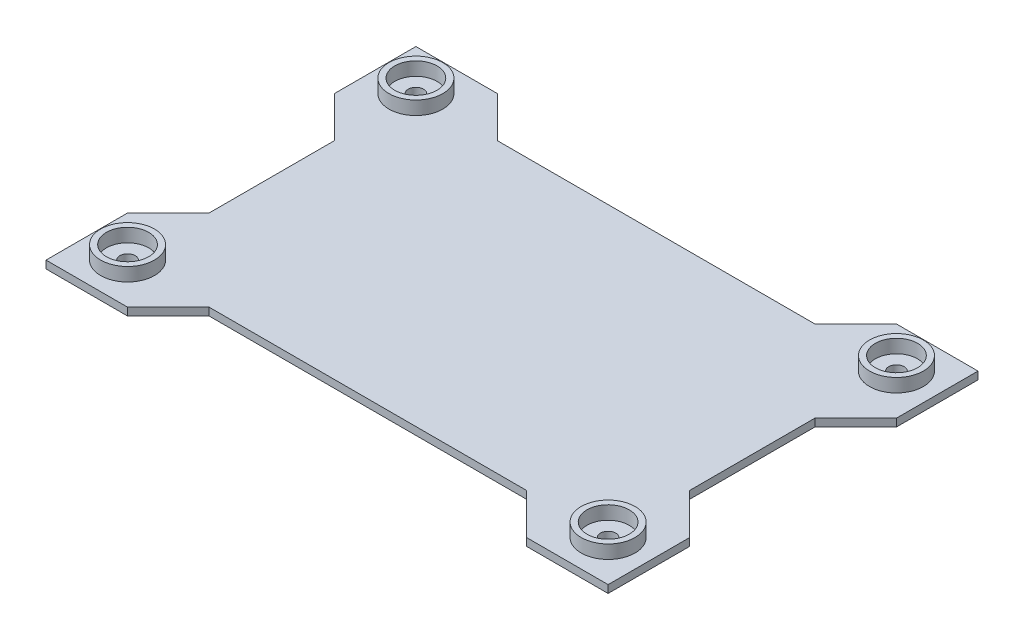
from build123d import *

# Parameters (mm, degrees)
SKETCH2_W                 = 250
SKETCH2_H                 = 150
BOSS_EXTRUDE1_DEPTH       = 4
BOSS_EXTRUDE2_DEPTH       = 4
SKETCH4_R                 = 4
CUT_EXTRUDE1_DEPTH        = 5
SKETCH5_R                 = 14
SKETCH5_R_2               = 11
BOSS_EXTRUDE3_DEPTH       = 7
MIRROR2_COPY_1_DEPTH      = 4
MIRROR2_COPY_2_SKETCH_R   = 4
MIRROR2_COPY_2_DEPTH      = 5
MIRROR2_COPY_3_SKETCH_R   = 14
MIRROR2_COPY_3_SKETCH_R_2 = 11
MIRROR2_COPY_3_DEPTH      = 7


with BuildPart() as part:
    # Sketch2 → Boss-Extrude1 (new body)
    with BuildSketch(Plane(origin=(0, 0, 0), x_dir=(1, 0, 0), z_dir=(0, 1, 0))):
        Rectangle(SKETCH2_W, SKETCH2_H)
    extrude(amount=BOSS_EXTRUDE1_DEPTH)

    # Sketch3 → Boss-Extrude2 (add)
    with BuildSketch(Plane(origin=(0, 4, 0), x_dir=(1, 0, 0), z_dir=(0, 1, 0))):
        Polygon((-103.786796564, 96.213203436), (-82.573593129, 75), (-125, 75), (-125, 32.573593129), (-146.213203436, 53.786796564), (-146.213203436, 96.213203436), align=None)
    boss_extrude2 = extrude(amount=-BOSS_EXTRUDE2_DEPTH)

    # Sketch4 → Cut-Extrude1 (cut, through all)
    with BuildSketch(Plane(origin=(0, 4, 0), x_dir=(1, 0, 0), z_dir=(0, 1, 0))):
        with Locations((-125, 75)):
            Circle(SKETCH4_R)
    cut_extrude1 = extrude(amount=-CUT_EXTRUDE1_DEPTH, mode=Mode.SUBTRACT)

    # Sketch5 → Boss-Extrude3 (add)
    with BuildSketch(Plane(origin=(0, 4, 0), x_dir=(1, 0, 0), z_dir=(0, 1, 0))):
        with Locations((-125, 75)):
            Circle(SKETCH5_R)
        with Locations((-125, 75)):
            Circle(SKETCH5_R_2, mode=Mode.SUBTRACT)
    boss_extrude3 = extrude(amount=BOSS_EXTRUDE3_DEPTH)

    # Mirror1: Boss-Extrude2, Cut-Extrude1, Boss-Extrude3 across plane
    add(boss_extrude2.mirror(Plane(origin=(0, 0, 0), x_dir=(0, 0, 1), z_dir=(1, 0, 0))))
    add(cut_extrude1.mirror(Plane(origin=(0, 0, 0), x_dir=(0, 0, 1), z_dir=(1, 0, 0))), mode=Mode.SUBTRACT)
    add(boss_extrude3.mirror(Plane(origin=(0, 0, 0), x_dir=(0, 0, 1), z_dir=(1, 0, 0))))

    # Mirror2: Boss-Extrude2, Cut-Extrude1, Boss-Extrude3 across plane
    add(boss_extrude2.mirror(Plane.XY))
    add(cut_extrude1.mirror(Plane.XY), mode=Mode.SUBTRACT)
    add(boss_extrude3.mirror(Plane.XY))

    # Mirror2 copy 1 sketch → Mirror2 copy 1 (add)
    with BuildSketch(Plane(origin=(0, 4, 0), x_dir=(-1, 0, 0), z_dir=(0, 1, 0))):
        Polygon((-103.786796564, 96.213203436), (-82.573593129, 75), (-125, 75), (-125, 32.573593129), (-146.213203436, 53.786796564), (-146.213203436, 96.213203436), align=None)
    extrude(amount=-MIRROR2_COPY_1_DEPTH)

    # Mirror2 copy 2 sketch → Mirror2 copy 2 (cut, through all)
    with BuildSketch(Plane(origin=(0, 4, 0), x_dir=(-1, 0, 0), z_dir=(0, 1, 0))):
        with Locations((-125, 75)):
            Circle(MIRROR2_COPY_2_SKETCH_R)
    extrude(amount=-MIRROR2_COPY_2_DEPTH, mode=Mode.SUBTRACT)

    # Mirror2 copy 3 sketch → Mirror2 copy 3 (add)
    with BuildSketch(Plane(origin=(0, 4, 0), x_dir=(-1, 0, 0), z_dir=(0, 1, 0))):
        with Locations((-125, 75)):
            Circle(MIRROR2_COPY_3_SKETCH_R)
        with Locations((-125, 75)):
            Circle(MIRROR2_COPY_3_SKETCH_R_2, mode=Mode.SUBTRACT)
    extrude(amount=MIRROR2_COPY_3_DEPTH)


solid = part.part
